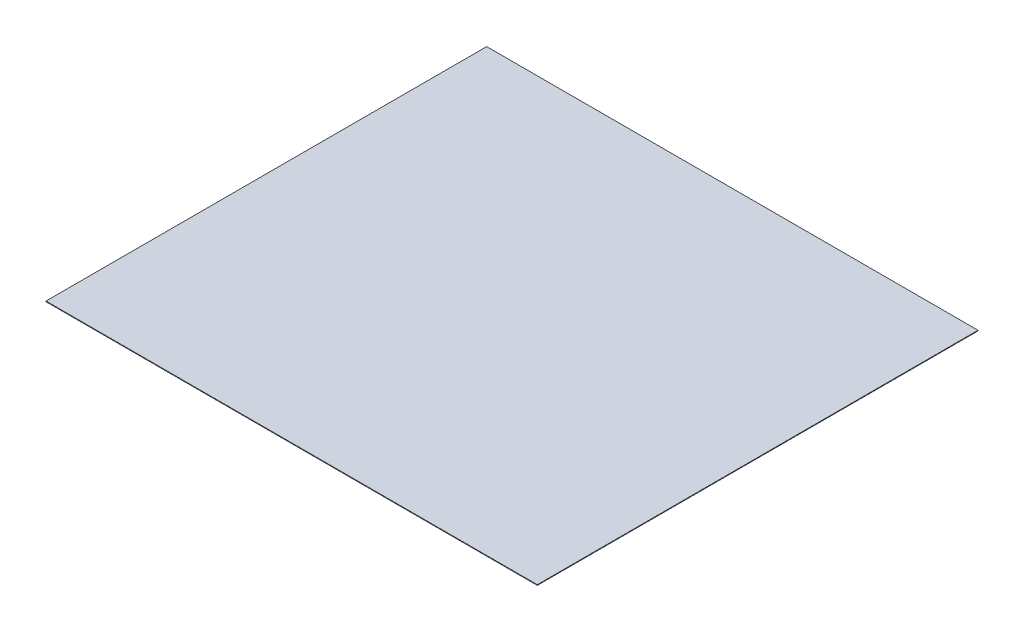
from build123d import *

# Parameters (mm, degrees)
SKETCH1_W           = 7804
SKETCH1_H           = 7000
BOSS_EXTRUDE1_DEPTH = 10


with BuildPart() as part:
    # Sketch1 → Boss-Extrude1 (new body)
    with BuildSketch(Plane(origin=(0, 0, 0), x_dir=(1, 0, 0), z_dir=(0, 1, 0))):
        Rectangle(SKETCH1_W, SKETCH1_H)
    extrude(amount=BOSS_EXTRUDE1_DEPTH)


solid = part.part
